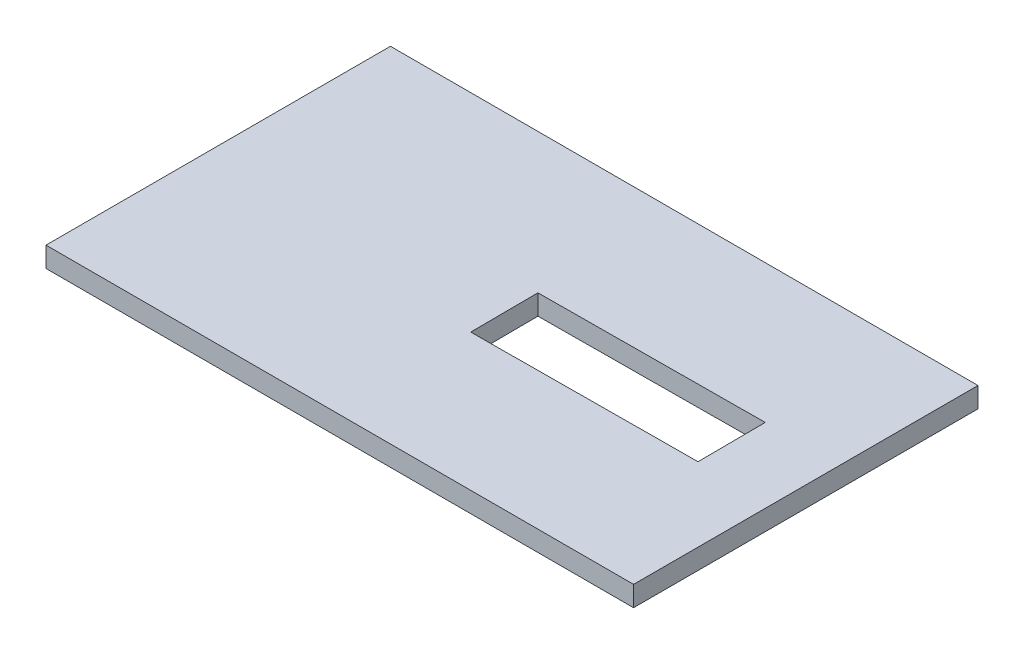
from build123d import *

# Parameters (mm, degrees)
SKETCH_1_W          = 5800
SKETCH_1_H          = 3400
EXTRUDE_1_DEPTH     = 200
CUT_EXTRUDE_1_DEPTH = 200


with BuildPart() as part:
    # Эскиз1 → Бобышка-Вытянуть1 (new body)
    with BuildSketch(Plane(origin=(0, 0, 0), x_dir=(1, 0, 0), z_dir=(0, 1, 0))):
        with Locations((2900, 1700)):
            Rectangle(SKETCH_1_W, SKETCH_1_H)
    extrude(amount=EXTRUDE_1_DEPTH)

    # Эскиз2 → Вырез-Вытянуть1 (cut)
    with BuildSketch(Plane(origin=(0, 200, 0), x_dir=(1, 0, 0), z_dir=(0, 1, 0))):
        Polygon((2835.64978703, 2020.278779221), (5065.60825261, 2034.049335389), (5069.729424565, 1366.68033616), (2839.770958985, 1352.909779993), align=None)
    extrude(amount=-CUT_EXTRUDE_1_DEPTH, mode=Mode.SUBTRACT)


solid = part.part
